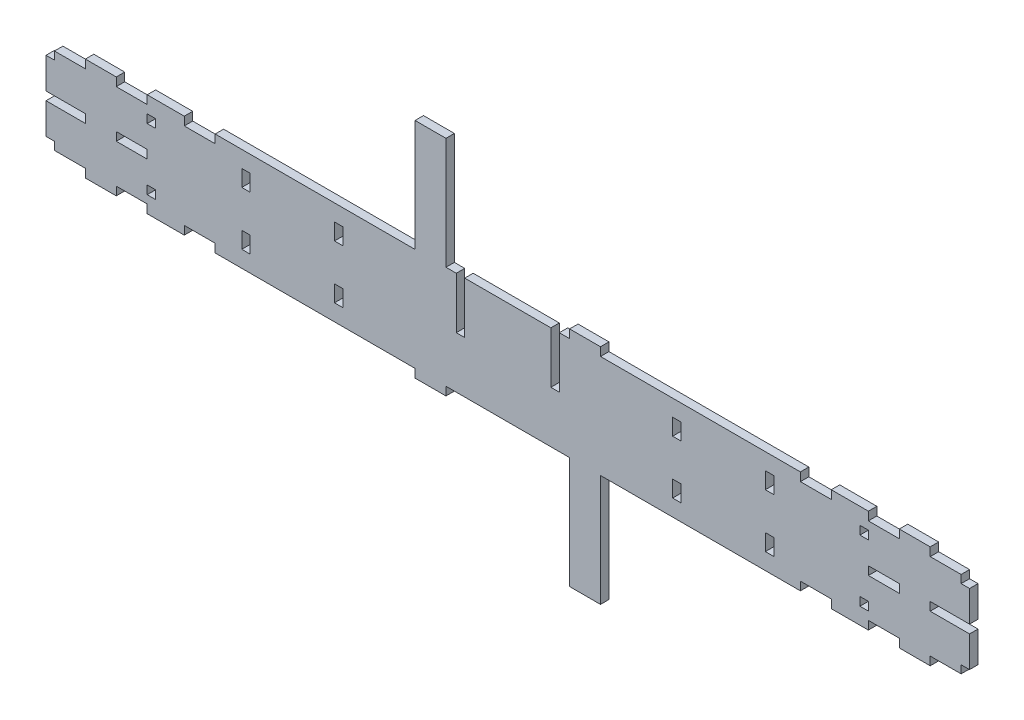
from build123d import *

# Parameters (mm, degrees)
SKETCH1_W           = 4.1
SKETCH1_H           = 4.1
SKETCH1_H_2         = 8
SKETCH1_W_2         = 15
BOSS_EXTRUDE1_DEPTH = 4.1
SKETCH2_W           = 15
SKETCH2_H           = 4.1
TOP_RIGHT_DEPTH     = 50.1
SKETCH3_W           = 15
SKETCH3_H           = 4.1
BOTTOM_LEFT_DEPTH   = 50.1


with BuildPart() as part:
    # Sketch1 → Boss-Extrude1 (new body)
    with BuildSketch(Plane.XY):
        Polygon((-205, -20.9), (-205, -25), (-190, -25), (-190, -20.9), (-175, -20.9), (-175, -25), (-157, -25), (-157, -20.9), (-142, -20.9), (-142, -25), (-45, -25), (-45, -79.2), (-30, -79.2), (-30, -25), (30, -25), (30, -79.2), (45, -79.2), (45, -25), (142, -25), (142, -20.9), (157, -20.9), (157, -25), (175, -25), (175, -20.9), (190, -20.9), (190, -25), (205, -25), (205, -20.9), (220, -20.9), (220, -17.05), (224.1, -17.05), (224.1, -2.05), (205, -2.05), (205, 2.05), (224.1, 2.05), (224.1, 17.05), (220, 17.05), (220, 20.9), (205, 20.9), (205, 25), (190, 25), (190, 20.9), (175, 20.9), (175, 25), (157, 25), (157, 20.9), (142, 20.9), (142, 25), (45, 25), (45, 79.2), (30, 79.2), (30, 25), (25, 25), (25, 0), (20.9, 0), (20.9, 25), (-20.9, 25), (-20.9, 0), (-25, 0), (-25, 25), (-30, 25), (-30, 79.2), (-45, 79.2), (-45, 25), (-142, 25), (-142, 20.9), (-157, 20.9), (-157, 25), (-175, 25), (-175, 20.9), (-190, 20.9), (-190, 25), (-205, 25), (-205, 20.9), (-220, 20.9), (-220, 17.05), (-224.1, 17.05), (-224.1, 2.05), (-205, 2.05), (-205, -2.05), (-224.1, -2.05), (-224.1, -17.05), (-220, -17.05), (-220, -20.9), align=None)
        with Locations((-172.95, -14.95)):
            Rectangle(SKETCH1_W, SKETCH1_H, mode=Mode.SUBTRACT)
        with Locations((-127.05, -13)):
            Rectangle(SKETCH1_W, SKETCH1_H_2, mode=Mode.SUBTRACT)
        with Locations((-82.05, -13)):
            Rectangle(SKETCH1_W, SKETCH1_H_2, mode=Mode.SUBTRACT)
        with Locations((82.05, -13)):
            Rectangle(SKETCH1_W, SKETCH1_H_2, mode=Mode.SUBTRACT)
        with Locations((127.05, -13)):
            Rectangle(SKETCH1_W, SKETCH1_H_2, mode=Mode.SUBTRACT)
        with Locations((172.95, -14.95)):
            Rectangle(SKETCH1_W, SKETCH1_H, mode=Mode.SUBTRACT)
        with Locations((-182.5, 0)):
            Rectangle(SKETCH1_W_2, SKETCH1_H, mode=Mode.SUBTRACT)
        with Locations((-172.95, 14.95)):
            Rectangle(SKETCH1_W, SKETCH1_H, mode=Mode.SUBTRACT)
        with Locations((-127.05, 13)):
            Rectangle(SKETCH1_W, SKETCH1_H_2, mode=Mode.SUBTRACT)
        with Locations((-82.05, 13)):
            Rectangle(SKETCH1_W, SKETCH1_H_2, mode=Mode.SUBTRACT)
        with Locations((82.05, 13)):
            Rectangle(SKETCH1_W, SKETCH1_H_2, mode=Mode.SUBTRACT)
        with Locations((127.05, 13)):
            Rectangle(SKETCH1_W, SKETCH1_H_2, mode=Mode.SUBTRACT)
        with Locations((182.5, 0)):
            Rectangle(SKETCH1_W_2, SKETCH1_H, mode=Mode.SUBTRACT)
        with Locations((172.95, 14.95)):
            Rectangle(SKETCH1_W, SKETCH1_H, mode=Mode.SUBTRACT)
    extrude(amount=BOSS_EXTRUDE1_DEPTH)

    # Sketch2 → top right (cut)
    with BuildSketch(Plane(origin=(0, 79.2, 0), x_dir=(1, 0, 0), z_dir=(0, 1, 0))):
        with Locations((37.5, -2.05)):
            Rectangle(SKETCH2_W, SKETCH2_H)
    extrude(amount=-TOP_RIGHT_DEPTH, mode=Mode.SUBTRACT)

    # Sketch3 → bottom left (cut)
    with BuildSketch(Plane.XZ.offset(79.2)):
        with Locations((-37.5, 2.05)):
            Rectangle(SKETCH3_W, SKETCH3_H)
    extrude(amount=-BOTTOM_LEFT_DEPTH, mode=Mode.SUBTRACT)


solid = part.part
